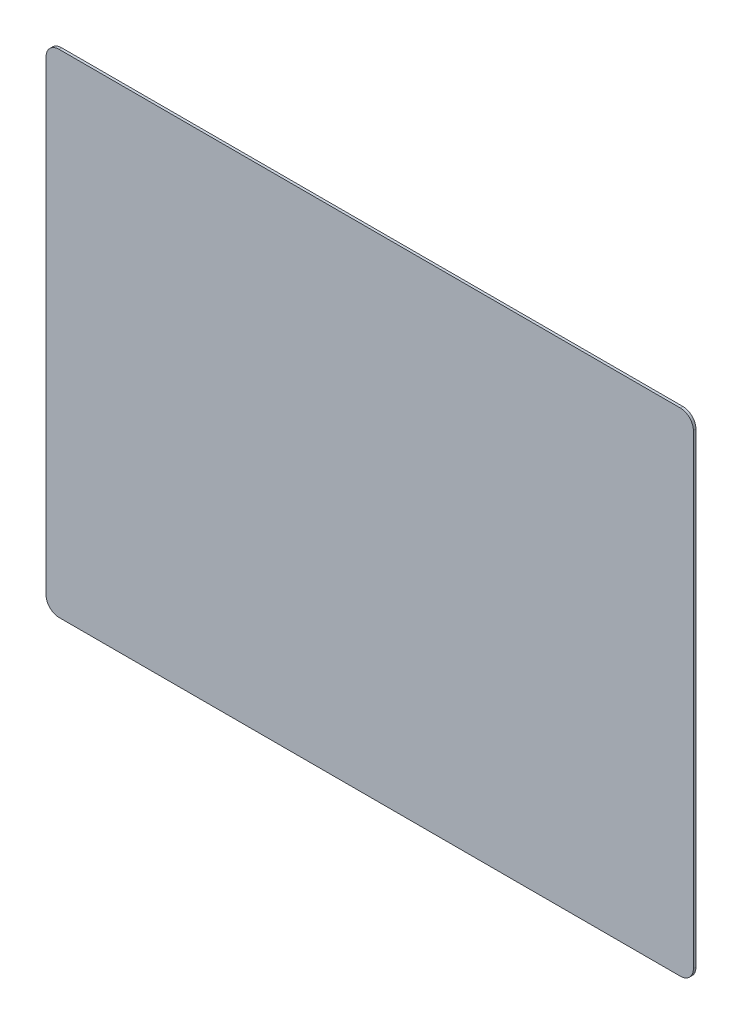
from build123d import *

# Parameters (mm, degrees)
SKETCH1_W           = 997
SKETCH1_H           = 758
BOSS_EXTRUDE1_DEPTH = 4
FILLET1_R           = 20


with BuildPart() as part:
    # Sketch1 → Boss-Extrude1 (new body)
    with BuildSketch(Plane.XY):
        Rectangle(SKETCH1_W, SKETCH1_H)
    extrude(amount=BOSS_EXTRUDE1_DEPTH)

    # Fillet1
    fillet1_edges = [part.edges().sort_by_distance(p)[0] for p in [
        (498.5, -379, 2),
        (-498.5, -379, 2),
        (-498.5, 379, 2),
        (498.5, 379, 2),
    ]]
    fillet(fillet1_edges, radius=FILLET1_R)


solid = part.part
